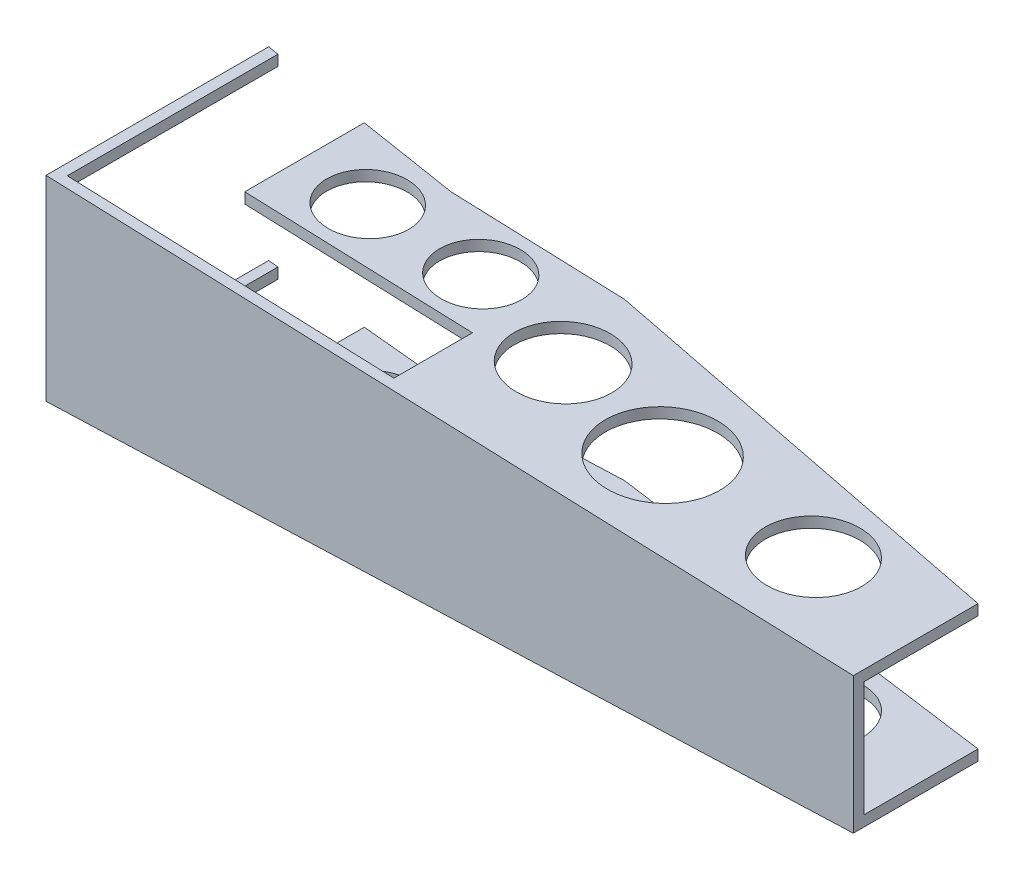
from build123d import *

# Parameters (mm, degrees)
BOSS_EXTRUDE1_DEPTH     = 105
CUT_EXTRUDE1_DEPTH      = 105.1
CUT_EXTRUDE1_DEPTH_BACK = 105.1
CUT_EXTRUDE4_DEPTH      = 346.052587439
CUT_EXTRUDE4_DEPTH_BACK = 346.052587439
SKETCH8_R               = 23.092737718
SKETCH8_R_2             = 19.459118311
CUT_EXTRUDE5_DEPTH      = 346.052587439
CUT_EXTRUDE5_DEPTH_BACK = 346.052587439
SKETCH9_R               = 16.617220832
SKETCH9_R_2             = 16.520725145
SKETCH9_R_3             = 19.698995854


with BuildPart() as part:
    # Sketch1 → Boss-Extrude1 (new body)
    with BuildSketch(Plane.XY):
        Polygon((0, 39.555), (0, -39.555), (326.3, -27.585), (326.3, 27.585), align=None)
    extrude(amount=BOSS_EXTRUDE1_DEPTH)

    # Sketch3 → Cut-Extrude1 (cut, two sides: drawn at the far end of the back side and taken through both)
    with BuildSketch(Plane(origin=(0, 0, 0), x_dir=(1, 0, 0), z_dir=(0, 1, 0)).offset(-CUT_EXTRUDE1_DEPTH_BACK)):
        Polygon((0, -15), (84.7, -25.82), (154.7, -25.82), (326.3, -54.6), (326.3, 36.079011671), (0, 41.113860107), align=None)
    extrude(amount=CUT_EXTRUDE1_DEPTH + CUT_EXTRUDE1_DEPTH_BACK, mode=Mode.SUBTRACT)

    # Sketch4 → Cut-Loft1 section 0
    with BuildSketch(Plane(origin=(326.3, 0, 0), x_dir=(0, 0, -1), z_dir=(1, 0, 0))):
        with BuildLine():
            Line((-100.7, 23.285), (-22.554524003, 23.285))
            Line((-22.554524003, 23.285), (-22.554524003, -23.285))
            Line((-22.554524003, -23.285), (-100.7, -23.285))
            Line((-100.7, -23.285), (-100.7, 23.285))
        make_face()
    # Sketch5 → Cut-Loft1 section 1
    with BuildSketch(Plane.ZY):
        with BuildLine():
            Line((-10.956527507, 35.255), (100.7, 35.255))
            Line((100.7, 35.255), (100.7, -35.255))
            Line((100.7, -35.255), (-10.956527507, -35.255))
            Line((-10.956527507, -35.255), (-10.956527507, 35.255))
        make_face()
    loft(mode=Mode.SUBTRACT)

    # Sketch8 → Cut-Extrude4 (cut, two sides: drawn at the far end of the back side and taken through both)
    with BuildSketch(Plane(origin=(0, 0, 0), x_dir=(1, 0, 0), z_dir=(0, 1, 0)).offset(-CUT_EXTRUDE4_DEPTH_BACK)):
        with Locations((214.641912664, -70.440417493)):
            Circle(SKETCH8_R)
        with Locations((278.393804533, -73.204497515)):
            Circle(SKETCH8_R_2)
    extrude(amount=CUT_EXTRUDE4_DEPTH + CUT_EXTRUDE4_DEPTH_BACK, mode=Mode.SUBTRACT)

    # Sketch9 → Cut-Extrude5 (cut, two sides: drawn at the far end of the back side and taken through both)
    with BuildSketch(Plane(origin=(0, 0, 0), x_dir=(1, 0, 0), z_dir=(0, 1, 0)).offset(-CUT_EXTRUDE5_DEPTH_BACK)):
        with Locations((118.110707971, -47.394014977)):
            Circle(SKETCH9_R)
        with Locations((72.426153878, -47.394014977)):
            Circle(SKETCH9_R_2)
        with Locations((164.053366889, -60.04115142)):
            Circle(SKETCH9_R_3)
        Polygon((4.3, -6.491738735), (44.3, -6.491738735), (44.3, -68.95), (136.3, -68.95), (136.3, -100.7), (44.3, -100.7), (4.3, -100.7), align=None)
    extrude(amount=CUT_EXTRUDE5_DEPTH + CUT_EXTRUDE5_DEPTH_BACK, mode=Mode.SUBTRACT)


solid = part.part
